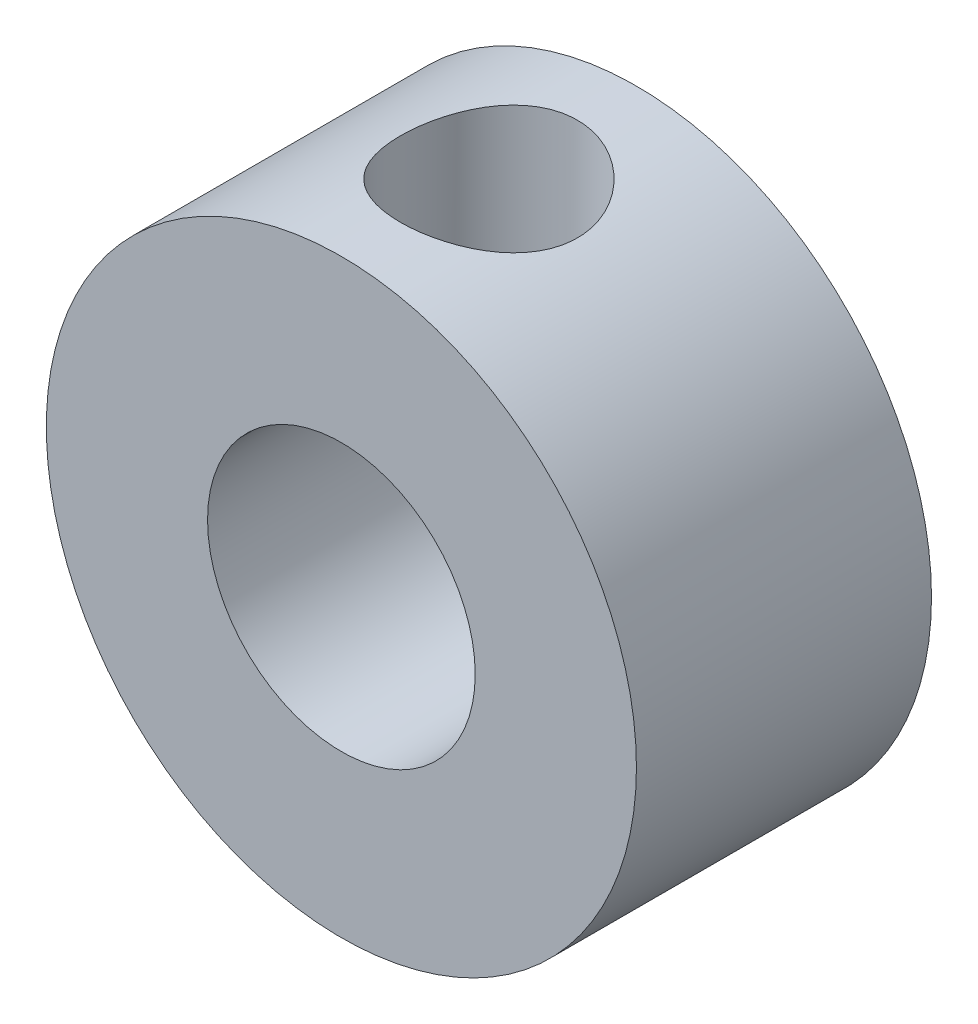
from build123d import *

# Parameters (mm, degrees)
SKETCH1_R                  = 7
SKETCH1_R_2                = 3.175
BOSS_EXTRUDE1_DEPTH        = 7
M5X0_8_TAPPED_HOLE1_REACH  = 19.146
M5X0_8_TAPPED_HOLE1_BORE_R = 2.1


with BuildPart() as part:
    # Sketch1 → Boss-Extrude1 (new body)
    with BuildSketch(Plane.XY):
        Circle(SKETCH1_R)
        Circle(SKETCH1_R_2, mode=Mode.SUBTRACT)
    extrude(amount=BOSS_EXTRUDE1_DEPTH)

    # M5x0.8 Tapped Hole1 bore → M5x0.8 Tapped Hole1 (cut, up to next)
    with BuildSketch(Plane(origin=(0, 7, 0), x_dir=(1, 0, 0), z_dir=(0, 1, 0)), mode=Mode.PRIVATE) as m5x0_8_tapped_hole1_sk1:
        with Locations((0, -3.5)):
            Circle(M5X0_8_TAPPED_HOLE1_BORE_R)
    m5x0_8_tapped_hole1_tool1 = extrude(m5x0_8_tapped_hole1_sk1.sketch, amount=-M5X0_8_TAPPED_HOLE1_REACH, mode=Mode.PRIVATE) & part.part
    add(m5x0_8_tapped_hole1_tool1.solids().sort_by_distance((0, 7, 3.5))[0], mode=Mode.SUBTRACT)


solid = part.part
